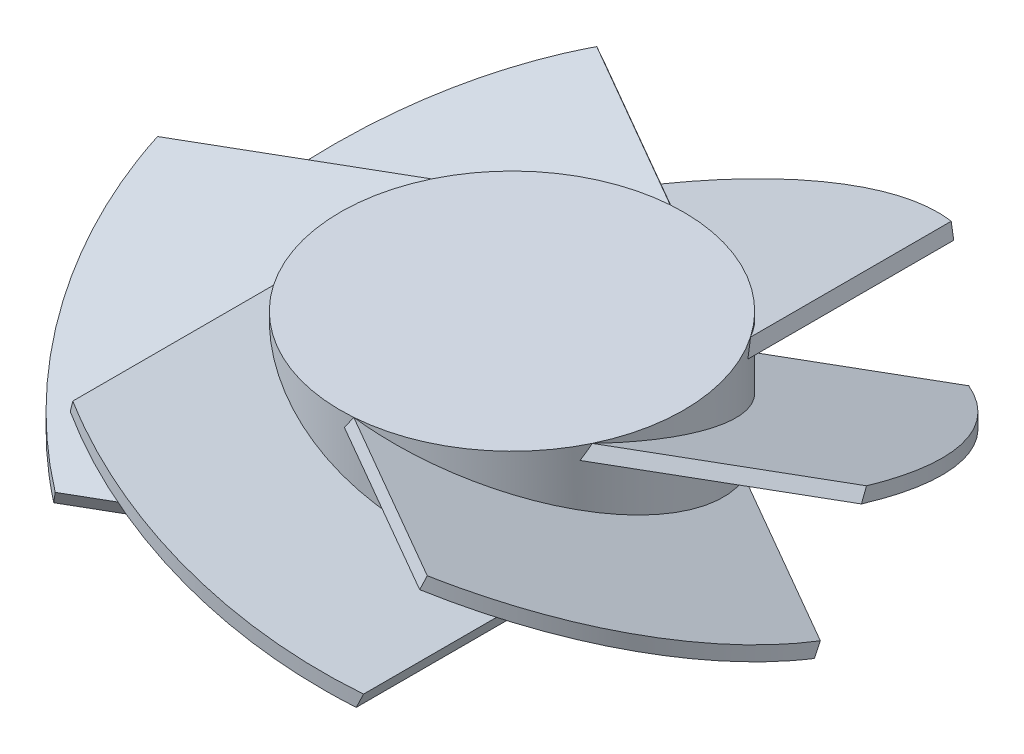
from build123d import *

# Parameters (mm, degrees)
SKETCH1_R           = 25
BOSS_EXTRUDE1_DEPTH = 18
BOSS_EXTRUDE2_DEPTH = 38
CIRPATTERN1_COUNT   = 6
SKETCH4_R           = 55.206013126
SKETCH4_R_2         = 48
CUT_EXTRUDE2_DEPTH  = 38


with BuildPart() as part:
    # Sketch1 → Boss-Extrude1 (new body)
    with BuildSketch(Plane(origin=(0, 0, 0), x_dir=(1, 0, 0), z_dir=(0, 1, 0))):
        Circle(SKETCH1_R)
    extrude(amount=BOSS_EXTRUDE1_DEPTH)

    # Sketch3 → Boss-Extrude2 (add)
    with BuildSketch(Plane(origin=(0, 0, 48), x_dir=(-1, 0, 0), z_dir=(0, 0, -1))):
        Polygon((-21.362842742, 1.867051803), (20.645822822, 18), (21.362842742, 16.132948197), (-20.645822822, 0), align=None)
    boss_extrude2 = extrude(amount=BOSS_EXTRUDE2_DEPTH)

    # CirPattern1: Boss-Extrude2 ×6 about axis
    cirpattern1_axis = Axis((0, 0, 0), (0, 1, 0))
    for i in range(1, CIRPATTERN1_COUNT):
        add(boss_extrude2.rotate(cirpattern1_axis, i * 360 / CIRPATTERN1_COUNT))

    # Sketch4 → Cut-Extrude2 (cut)
    with BuildSketch(Plane(origin=(0, 18, 0), x_dir=(1, 0, 0), z_dir=(0, 1, 0))):
        Circle(SKETCH4_R)
        Circle(SKETCH4_R_2, mode=Mode.SUBTRACT)
    extrude(amount=-CUT_EXTRUDE2_DEPTH, mode=Mode.SUBTRACT)


solid = part.part
